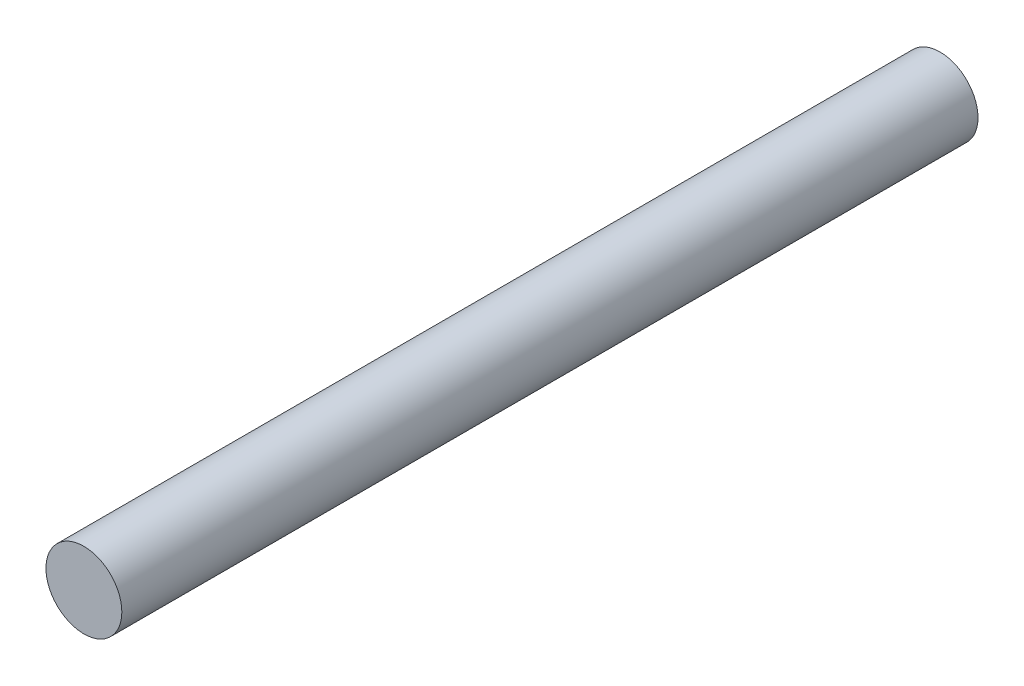
from build123d import *

# Parameters (mm, degrees)
SALIENTE_EXTRUIR6_DEPTH      = 5
SALIENTE_EXTRUIR6_DEPTH_BACK = 10
CROQUIS9_R                   = 0.665


with BuildPart() as part:
    # Croquis9 → Saliente-Extruir6 (new, two sides: drawn at the far end of the back side and taken through both)
    with BuildSketch(Plane.XY.offset(-SALIENTE_EXTRUIR6_DEPTH_BACK)):
        with Locations((156.320949509, 0)):
            Circle(CROQUIS9_R)
    extrude(amount=SALIENTE_EXTRUIR6_DEPTH + SALIENTE_EXTRUIR6_DEPTH_BACK)


solid = part.part
